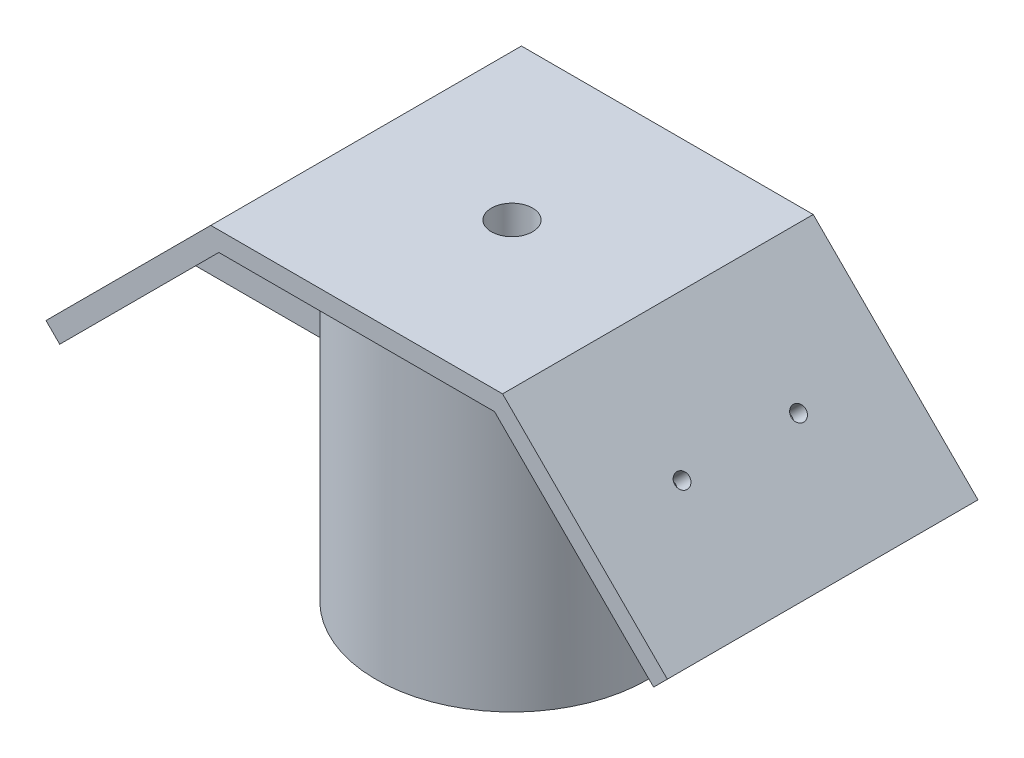
from build123d import *

# Parameters (mm, degrees)
BOSS_EXTRUDE1_DEPTH = 50.8
BOSS_EXTRUDE3_START = 50.8
SKETCH4_R           = 22.225
BOSS_EXTRUDE3_DEPTH = 50.8
SKETCH8_W           = 6.35
SKETCH8_H           = 36.78487194
BOSS_EXTRUDE5_DEPTH = 26.649040147
CIRPATTERN2_COUNT   = 2
CIRPATTERN2_ANGLE   = 180
SKETCH9_R           = 3.3655
CUT_EXTRUDE1_DEPTH  = 90.858670283
CUT_EXTRUDE2_REACH  = 109.65
SKETCH10_R          = 1.190625


with BuildPart() as part:
    # Sketch1 → Boss-Extrude1 (new body)
    with BuildSketch(Plane.XY):
        Polygon((-50.8, 14.559871939), (-23.859231637, 41.500640303), (23.859231637, 41.500640303), (50.8, 14.559871939), (48.55493597, 12.314807909), (22.544103576, 38.325640303), (-22.544103576, 38.325640303), (-48.55493597, 12.314807909), align=None)
    extrude(amount=BOSS_EXTRUDE1_DEPTH)

    # Sketch4 → Boss-Extrude3 (add)
    with BuildSketch(Plane.XZ.offset(-38.325640303).offset(BOSS_EXTRUDE3_START)):
        with Locations((0, 25.4)):
            Circle(SKETCH4_R)
    extrude(amount=-BOSS_EXTRUDE3_DEPTH)

    # Sketch8 → Boss-Extrude5 (add, along a direction that is not the sketch's normal)
    with BuildSketch(Plane(origin=(-30.434871939, 30.434871939, 0), x_dir=(0, 0, -1), z_dir=(0.7071067811865515, -0.7071067811865436, 0))):
        with Locations((-25.4, -7.233204333)):
            Rectangle(SKETCH8_W, SKETCH8_H)
    boss_extrude5 = extrude(amount=BOSS_EXTRUDE5_DEPTH, dir=(1, 0, 0))

    # CirPattern2: Boss-Extrude5 ×2 about axis
    cirpattern2_axis = Axis((0, 101.18743315, 25.4), (0, -1, 0))
    for i in range(1, CIRPATTERN2_COUNT):
        add(boss_extrude5.rotate(cirpattern2_axis, i * CIRPATTERN2_ANGLE / (CIRPATTERN2_COUNT - 1)))

    # Sketch9 → Cut-Extrude1 (cut, through all)
    with BuildSketch(Plane(origin=(0, 41.500640303, 0), x_dir=(1, 0, 0), z_dir=(0, 1, 0))):
        with Locations(Location((0, -25.4, 0), (0, 0, 180))):
            Circle(SKETCH9_R)
    extrude(amount=-CUT_EXTRUDE1_DEPTH, mode=Mode.SUBTRACT)

    # Sketch10 → Cut-Extrude2 (cut, up to next)
    with BuildSketch(Plane(origin=(-32.67993597, 32.67993597, 0), x_dir=(0, 0, 1), z_dir=(-0.7071067811865517, 0.7071067811865434, 0)), mode=Mode.PRIVATE) as cut_extrude2_sk1:
        with Locations(Location((15.875, -6.575640303, 0), (0, 0, 270))):
            Circle(SKETCH10_R)
    cut_extrude2_tool1 = extrude(cut_extrude2_sk1.sketch, amount=-CUT_EXTRUDE2_REACH, mode=Mode.PRIVATE) & part.part
    # Sketch10 → Cut-Extrude2 (cut, up to next)
    with BuildSketch(Plane(origin=(-32.67993597, 32.67993597, 0), x_dir=(0, 0, 1), z_dir=(-0.7071067811865517, 0.7071067811865434, 0)), mode=Mode.PRIVATE) as cut_extrude2_sk2:
        with Locations(Location((34.925, -6.575640303, 0), (0, 0, 270))):
            Circle(SKETCH10_R)
    cut_extrude2_tool2 = extrude(cut_extrude2_sk2.sketch, amount=-CUT_EXTRUDE2_REACH, mode=Mode.PRIVATE) & part.part
    cut_extrude2_1 = cut_extrude2_tool1.solids().sort_by_distance((-37.329616, 28.030256, 15.875))[0]
    add(cut_extrude2_1, mode=Mode.SUBTRACT)
    cut_extrude2_2 = cut_extrude2_tool2.solids().sort_by_distance((-37.329616, 28.030256, 34.925))[0]
    add(cut_extrude2_2, mode=Mode.SUBTRACT)
    cut_extrude2 = cut_extrude2_1 + cut_extrude2_2  # Cut-Extrude2 as one shape, for the pattern or mirror that repeats it

    # Mirror2: Cut-Extrude2 across plane
    add(cut_extrude2.mirror(Plane(origin=(0, 0, 0), x_dir=(0, 0, 1), z_dir=(1, 0, 0))), mode=Mode.SUBTRACT)


solid = part.part
